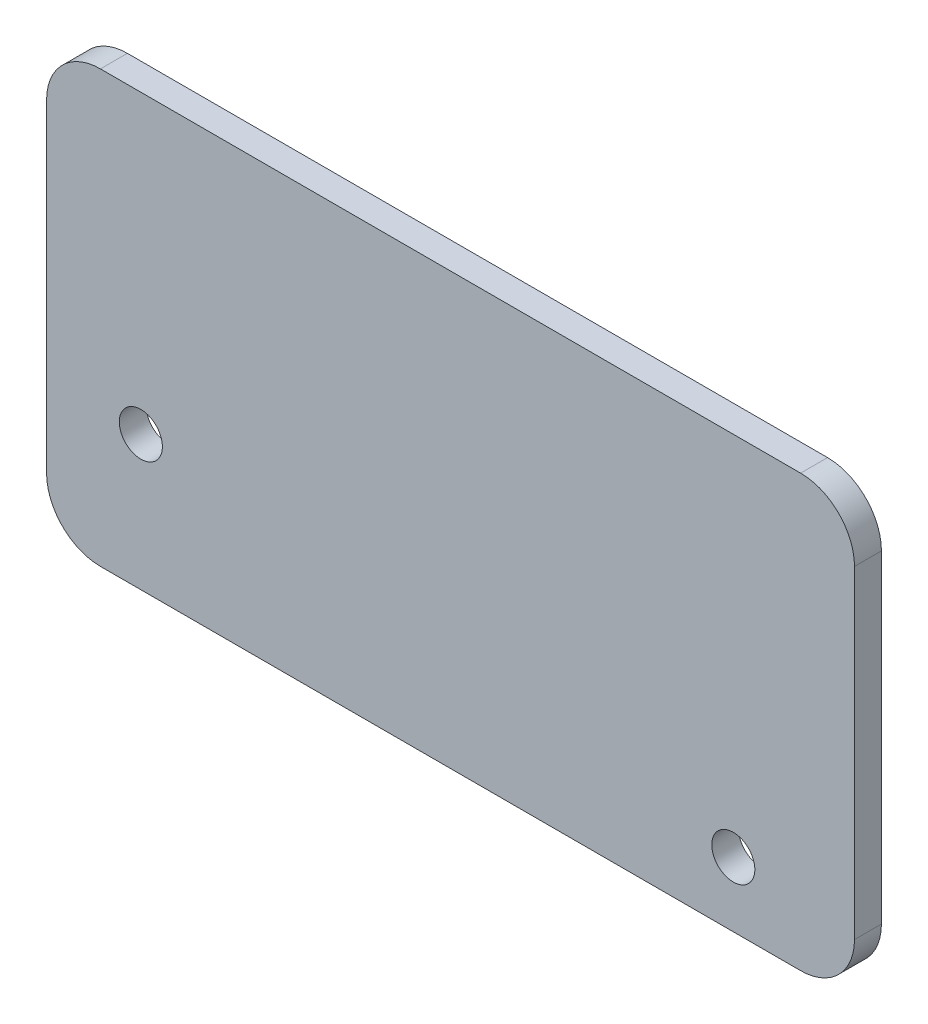
from build123d import *

# Parameters (mm, degrees)
SKETCH1_R           = 4
BOSS_EXTRUDE1_DEPTH = 5


with BuildPart() as part:
    # Sketch1 → Boss-Extrude1 (new body)
    with BuildSketch(Plane.XY):
        with BuildLine():
            Line((-65, 40), (65, 40))
            ThreePointArc((65, 40), (72.071067812, 37.071067812), (75, 30))
            Line((75, 30), (75, -30))
            ThreePointArc((75, -30), (72.071067812, -37.071067812), (65, -40))
            Line((65, -40), (-65, -40))
            ThreePointArc((-65, -40), (-72.071067812, -37.071067812), (-75, -30))
            Line((-75, -30), (-75, 30))
            ThreePointArc((-75, 30), (-72.071067812, 37.071067812), (-65, 40))
        make_face()
        with Locations((52.5, -28)):
            Circle(SKETCH1_R, mode=Mode.SUBTRACT)
        with Locations((-57.500017929, -15)):
            Circle(SKETCH1_R, mode=Mode.SUBTRACT)
    extrude(amount=BOSS_EXTRUDE1_DEPTH)


solid = part.part
